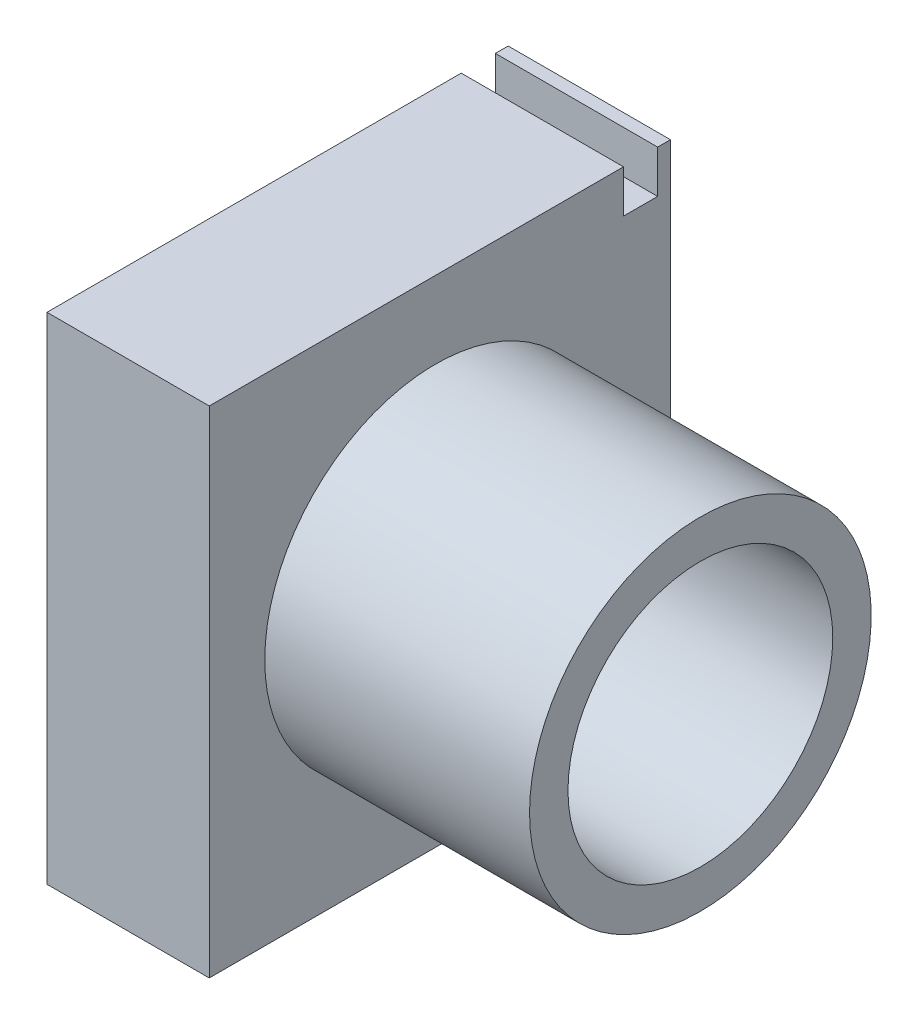
from build123d import *

# Parameters (mm, degrees)
SKETCH1_W           = 19
SKETCH1_H           = 58
BOSS_EXTRUDE1_DEPTH = 54
SKETCH2_3_R         = 20
SKETCH2_3_R_2       = 15.5
BOSS_EXTRUDE2_DEPTH = 50
SKETCH2_R           = 1.9
CUT_EXTRUDE1_DEPTH  = 10
FILLET1_R           = 10
BOSS_EXTRUDE3_DEPTH = 50
SKETCH4_R           = 1.25
CUT_EXTRUDE2_DEPTH  = 55
SKETCH5_W           = 17
SKETCH5_H           = 14
CUT_EXTRUDE3_DEPTH  = 2
SKETCH6_W           = 19
SKETCH6_H           = 4
CUT_EXTRUDE4_DEPTH  = 5
SKETCH7_W           = 17
SKETCH7_H           = 14
CUT_EXTRUDE5_DEPTH  = 53


with BuildPart() as part:
    # Sketch1 → Boss-Extrude1 (new body)
    with BuildSketch(Plane.XY):
        with Locations((9.5, 29)):
            Rectangle(SKETCH1_W, SKETCH1_H)
    extrude(amount=BOSS_EXTRUDE1_DEPTH)

    # Sketch2_3 → Boss-Extrude2 (add)
    with BuildSketch(Plane.ZY):
        with Locations((27.5, 29)):
            Circle(SKETCH2_3_R)
        with Locations((27.5, 29)):
            Circle(SKETCH2_3_R_2, mode=Mode.SUBTRACT)
    extrude(amount=-BOSS_EXTRUDE2_DEPTH)

    # Sketch2 → Cut-Extrude1 (cut)
    with BuildSketch(Plane.ZY):
        with Locations((9.25, 29)):
            Circle(SKETCH2_R)
        with Locations((45.75, 29)):
            Circle(SKETCH2_R)
    extrude(amount=-CUT_EXTRUDE1_DEPTH, mode=Mode.SUBTRACT)

    # Fillet1
    fillet1_edges = [part.edges().sort_by_distance(p)[0] for p in [
        (9.5, 0, 0),
    ]]
    fillet(fillet1_edges, radius=FILLET1_R)

    # Sketch3 → Boss-Extrude3 (add)
    with BuildSketch(Plane(origin=(0, 0, 0), x_dir=(0, 0, -1), z_dir=(1, 0, 0))):
        Polygon((0, 0), (0, 57), (0, 67), (-5, 67), (-5, 0), align=None)
    extrude(amount=-BOSS_EXTRUDE3_DEPTH)

    # Sketch4 → Cut-Extrude2 (cut, through all)
    with BuildSketch(Plane(origin=(0, 0, 0), x_dir=(-1, 0, 0), z_dir=(0, 0, -1))):
        with Locations((14, 57)):
            Circle(SKETCH4_R)
        Polygon((0, 53), (0, 0), (50, 0), (50, 67), (17, 67), (17, 53), align=None)
        with Locations((14, 63.5)):
            Circle(SKETCH4_R)
    extrude(amount=-CUT_EXTRUDE2_DEPTH, mode=Mode.SUBTRACT)

    # Sketch5 → Cut-Extrude3 (cut)
    with BuildSketch(Plane(origin=(0, 0, 0), x_dir=(-1, 0, 0), z_dir=(0, 0, -1))):
        with Locations((8.5, 60)):
            Rectangle(SKETCH5_W, SKETCH5_H)
    extrude(amount=-CUT_EXTRUDE3_DEPTH, mode=Mode.SUBTRACT)

    # Sketch6 → Cut-Extrude4 (cut)
    with BuildSketch(Plane(origin=(0, 58, 0), x_dir=(1, 0, 0), z_dir=(0, 1, 0))):
        with Locations((9.5, -3.5)):
            Rectangle(SKETCH6_W, SKETCH6_H)
    extrude(amount=-CUT_EXTRUDE4_DEPTH, mode=Mode.SUBTRACT)

    # Sketch7 → Cut-Extrude5 (cut, through all)
    with BuildSketch(Plane(origin=(0, 0, 2), x_dir=(-1, 0, 0), z_dir=(0, 0, -1))):
        with Locations((8.5, 60)):
            Rectangle(SKETCH7_W, SKETCH7_H)
    extrude(amount=-CUT_EXTRUDE5_DEPTH, mode=Mode.SUBTRACT)


solid = part.part
